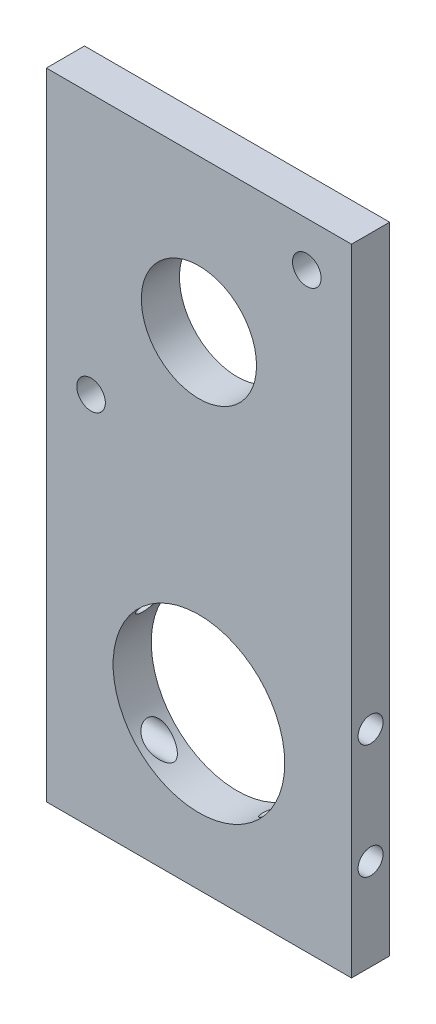
from build123d import *

# Parameters (mm, degrees)
SKETCH2_W           = 50.8
SKETCH2_H           = 105.799998966
SKETCH2_R           = 9.5885
SKETCH2_R_2         = 14.2875
SKETCH2_R_3         = 2.38125
BOSS_EXTRUDE1_DEPTH = 6.35
SKETCH6_R           = 2.0828
CUT_EXTRUDE1_DEPTH  = 51.8


with BuildPart() as part:
    # Sketch2 → Boss-Extrude1 (new body)
    with BuildSketch(Plane.XY):
        with Locations((0, -27.499999483)):
            Rectangle(SKETCH2_W, SKETCH2_H)
        Circle(SKETCH2_R, mode=Mode.SUBTRACT)
        with Locations((0, -54.999998966)):
            Circle(SKETCH2_R_2, mode=Mode.SUBTRACT)
        with Locations((-17.960512242, -17.960512242)):
            Circle(SKETCH2_R_3, mode=Mode.SUBTRACT)
        with Locations((17.960512242, 17.960512242)):
            Circle(SKETCH2_R_3, mode=Mode.SUBTRACT)
    extrude(amount=BOSS_EXTRUDE1_DEPTH)

    # Sketch6 → Cut-Extrude1 (cut, through all)
    with BuildSketch(Plane(origin=(25.4, 0, 0), x_dir=(0, 0, -1), z_dir=(1, 0, 0))):
        with Locations((-3.175, -65.159998966)):
            Circle(SKETCH6_R)
        with Locations((-3.175, -46.109998966)):
            Circle(SKETCH6_R)
    extrude(amount=-CUT_EXTRUDE1_DEPTH, mode=Mode.SUBTRACT)


solid = part.part
